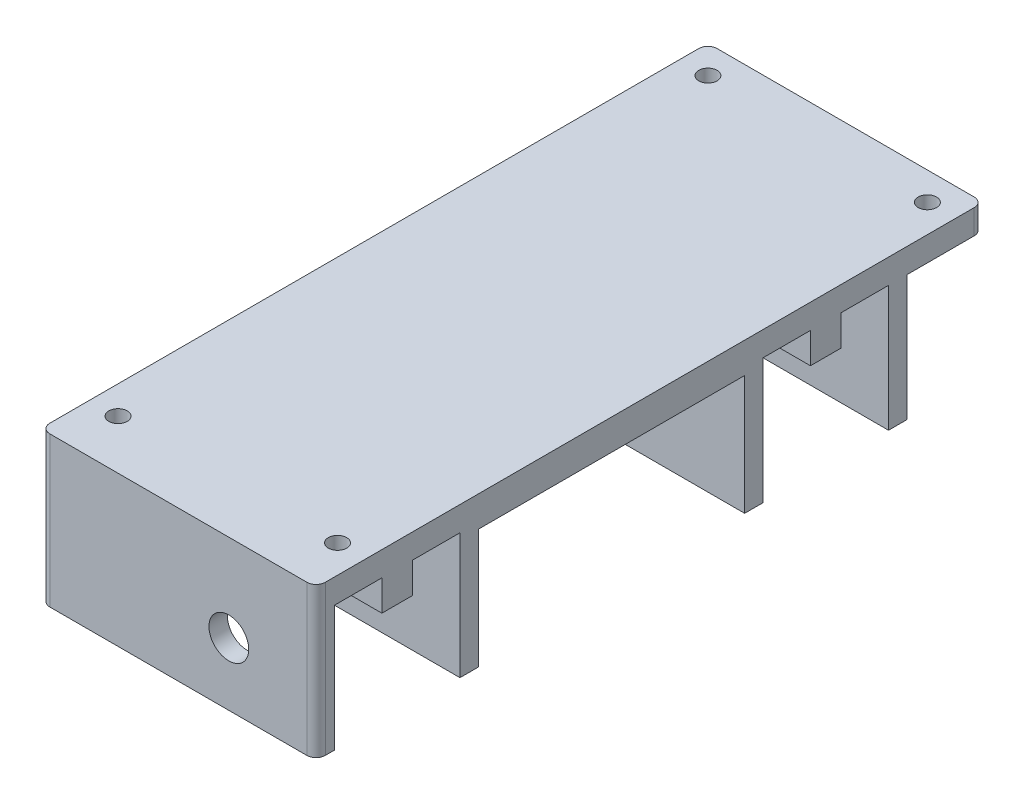
from build123d import *

# Parameters (mm, degrees)
SKETCH1_R           = 1.5
BOSS_EXTRUDE1_DEPTH = 4
SKETCH3_W           = 45
SKETCH3_H           = 3
SKETCH3_H_2         = 5
BOSS_EXTRUDE2_DEPTH = 20.5
SKETCH4_W           = 45
SKETCH4_H           = 5
CUT_EXTRUDE1_DEPTH  = 15.5
SKETCH5_W           = 45
SKETCH5_H           = 43.5
BOSS_EXTRUDE3_DEPTH = 1
SKETCH6_R           = 3.25
CUT_EXTRUDE2_DEPTH  = 103
SKETCH7_W           = 45
SKETCH7_H           = 3
BOSS_EXTRUDE4_DEPTH = 24.5


with BuildPart() as part:
    # Sketch1 → Boss-Extrude1 (new body)
    with BuildSketch(Plane(origin=(0, 0, 0), x_dir=(1, 0, 0), z_dir=(0, 1, 0))):
        with BuildLine():
            Line((21, -54.5), (-21, -54.5))
            ThreePointArc((-21, -54.5), (-22.060660172, -54.060660172), (-22.5, -53))
            Line((-22.5, -53), (-22.5, 53))
            ThreePointArc((-22.5, 53), (-22.060660172, 54.060660172), (-21, 54.5))
            Line((-21, 54.5), (21, 54.5))
            ThreePointArc((21, 54.5), (22.060660172, 54.060660172), (22.5, 53))
            Line((22.5, 53), (22.5, -53))
            ThreePointArc((22.5, -53), (22.060660172, -54.060660172), (21, -54.5))
        make_face()
        with Locations((17.925, -46.425)):
            Circle(SKETCH1_R, mode=Mode.SUBTRACT)
        with Locations((-17.925, -46.425)):
            Circle(SKETCH1_R, mode=Mode.SUBTRACT)
        with Locations((17.925, 49.925)):
            Circle(SKETCH1_R, mode=Mode.SUBTRACT)
        with Locations((-17.925, 49.925)):
            Circle(SKETCH1_R, mode=Mode.SUBTRACT)
    extrude(amount=-BOSS_EXTRUDE1_DEPTH)

    # Sketch3 → Boss-Extrude2 (add)
    with BuildSketch(Plane.XZ.offset(4)):
        with Locations((0, -17)):
            Rectangle(SKETCH3_W, SKETCH3_H)
        with Locations((0, -28.75)):
            Rectangle(SKETCH3_W, SKETCH3_H_2)
        with Locations((0, -40.5)):
            Rectangle(SKETCH3_W, SKETCH3_H)
        with Locations((0, 41.25)):
            Rectangle(SKETCH3_W, SKETCH3_H_2)
        with BuildLine():
            Line((-22.5, 51.5), (22.5, 51.5))
            Line((22.5, 51.5), (22.5, 53))
            ThreePointArc((22.5, 53), (22.060660172, 54.060660172), (21, 54.5))
            Line((21, 54.5), (-21, 54.5))
            ThreePointArc((-21, 54.5), (-22.060660172, 54.060660172), (-22.5, 53))
            Line((-22.5, 53), (-22.5, 51.5))
        make_face()
        with Locations((0, 29.5)):
            Rectangle(SKETCH3_W, SKETCH3_H)
    extrude(amount=BOSS_EXTRUDE2_DEPTH)

    # Sketch4 → Cut-Extrude1 (cut)
    with BuildSketch(Plane.XZ.offset(24.5)):
        with Locations((0, 41.25)):
            Rectangle(SKETCH4_W, SKETCH4_H)
        with Locations((0, -28.75)):
            Rectangle(SKETCH4_W, SKETCH4_H)
    extrude(amount=-CUT_EXTRUDE1_DEPTH, mode=Mode.SUBTRACT)

    # Sketch5 → Boss-Extrude3 (add)
    with BuildSketch(Plane.XZ.offset(4)):
        with Locations((0, 6.25)):
            Rectangle(SKETCH5_W, SKETCH5_H)
    extrude(amount=BOSS_EXTRUDE3_DEPTH)

    # Sketch6 → Cut-Extrude2 (cut)
    with BuildSketch(Plane.XY.offset(54.5)):
        with Locations((8.25, -14.25)):
            Circle(SKETCH6_R)
    extrude(amount=-CUT_EXTRUDE2_DEPTH, mode=Mode.SUBTRACT)

    # Sketch7 → Boss-Extrude4 (add)
    with BuildSketch(Plane.XZ.offset(24.5)):
        with Locations((0, 29.5)):
            Rectangle(SKETCH7_W, SKETCH7_H)
        with Locations((0, -17)):
            Rectangle(SKETCH7_W, SKETCH7_H)
    extrude(amount=-BOSS_EXTRUDE4_DEPTH)


solid = part.part
